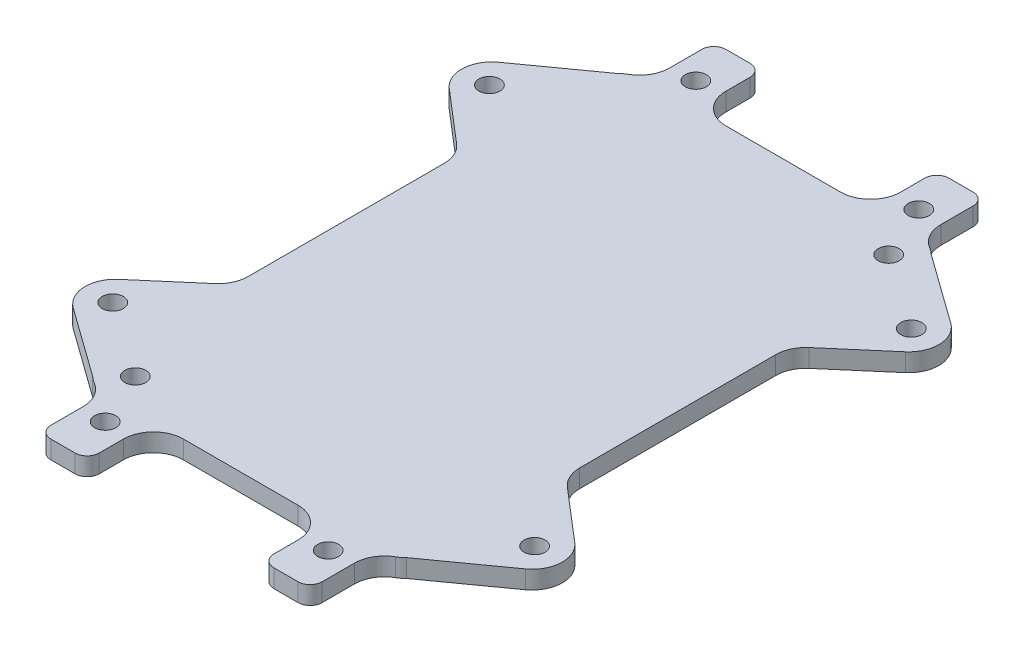
from build123d import *

# Parameters (mm, degrees)
SKETCH_1_R      = 1.75
EXTRUDE_1_DEPTH = 3
FILLET_3_R      = 5


with BuildPart() as part:
    # 草图1 → 凸台-拉伸1 (new body)
    with BuildSketch(Plane(origin=(0, 0, 0), x_dir=(1, 0, 0), z_dir=(0, 1, 0))):
        with BuildLine():
            Line((-27.5, -18.562205506), (-37.85023308, -27.436866757))
            ThreePointArc((-37.85023308, -27.436866757), (-39.59101252, -31.447551796), (-37.512145027, -35.293876989))
            Line((-37.512145027, -35.293876989), (-26.035533906, -43.535533906))
            ThreePointArc((-26.035533906, -43.535533906), (-24.413417162, -44.619397663), (-22.5, -45))
            Line((-22.5, -45), (-22.5, -54))
            ThreePointArc((-22.5, -54), (-21.914213562, -55.414213562), (-20.5, -56))
            Line((-20.5, -56), (-16.5, -56))
            ThreePointArc((-16.5, -56), (-15.085786438, -55.414213562), (-14.5, -54))
            Line((-14.5, -54), (-14.5, -45))
            Line((-14.5, -45), (14.5, -45))
            Line((14.5, -45), (14.5, -54))
            ThreePointArc((14.5, -54), (15.085786438, -55.414213562), (16.5, -56))
            Line((16.5, -56), (20.5, -56))
            ThreePointArc((20.5, -56), (21.914213562, -55.414213562), (22.5, -54))
            Line((22.5, -54), (22.5, -45))
            ThreePointArc((22.5, -45), (24.413417162, -44.619397663), (26.035533906, -43.535533906))
            Line((26.035533906, -43.535533906), (37.512145027, -35.293876989))
            ThreePointArc((37.512145027, -35.293876989), (39.59101252, -31.447551796), (37.85023308, -27.436866757))
            Line((37.85023308, -27.436866757), (27.5, -18.562205506))
            Line((27.5, -18.562205506), (27.5, 18.562205506))
            Line((27.5, 18.562205506), (37.85023308, 27.436866757))
            ThreePointArc((37.85023308, 27.436866757), (39.59101252, 31.447551796), (37.512145027, 35.293876989))
            Line((37.512145027, 35.293876989), (26.035533906, 43.535533906))
            ThreePointArc((26.035533906, 43.535533906), (24.413417162, 44.619397663), (22.5, 45))
            Line((22.5, 45), (22.5, 54))
            ThreePointArc((22.5, 54), (21.914213562, 55.414213562), (20.5, 56))
            Line((20.5, 56), (16.5, 56))
            ThreePointArc((16.5, 56), (15.085786438, 55.414213562), (14.5, 54))
            Line((14.5, 54), (14.5, 45))
            Line((14.5, 45), (-14.5, 45))
            Line((-14.5, 45), (-14.5, 54))
            ThreePointArc((-14.5, 54), (-15.085786438, 55.414213562), (-16.5, 56))
            Line((-16.5, 56), (-20.5, 56))
            ThreePointArc((-20.5, 56), (-21.914213562, 55.414213562), (-22.5, 54))
            Line((-22.5, 54), (-22.5, 45))
            ThreePointArc((-22.5, 45), (-24.413417162, 44.619397663), (-26.035533906, 43.535533906))
            Line((-26.035533906, 43.535533906), (-37.512145027, 35.293876989))
            ThreePointArc((-37.512145027, 35.293876989), (-39.59101252, 31.447551796), (-37.85023308, 27.436866757))
            Line((-37.85023308, 27.436866757), (-27.5, 18.562205506))
            Line((-27.5, 18.562205506), (-27.5, -18.562205506))
        make_face()
        with Locations((-22.5, -40)):
            Circle(SKETCH_1_R, mode=Mode.SUBTRACT)
        with Locations((22.5, 40)):
            Circle(SKETCH_1_R, mode=Mode.SUBTRACT)
        with Locations((-35, -31.25)):
            Circle(SKETCH_1_R, mode=Mode.SUBTRACT)
        with Locations((-18.5, -49)):
            Circle(SKETCH_1_R, mode=Mode.SUBTRACT)
        with Locations((18.5, -49)):
            Circle(SKETCH_1_R, mode=Mode.SUBTRACT)
        with Locations((-35, 31.25)):
            Circle(SKETCH_1_R, mode=Mode.SUBTRACT)
        with Locations((35, -31.25)):
            Circle(SKETCH_1_R, mode=Mode.SUBTRACT)
        with Locations((-18.5, 49)):
            Circle(SKETCH_1_R, mode=Mode.SUBTRACT)
        with Locations((35, 31.25)):
            Circle(SKETCH_1_R, mode=Mode.SUBTRACT)
        with Locations((18.5, 49)):
            Circle(SKETCH_1_R, mode=Mode.SUBTRACT)
    extrude(amount=EXTRUDE_1_DEPTH)

    # 圆角3
    fillet_3_edges = [part.edges().sort_by_distance(p)[0] for p in [
        (-22.5, 1.5, -45),
        (-14.5, 1.5, -45),
        (14.5, 1.5, -45),
        (22.5, 1.5, -45),
        (27.5, 1.5, -18.562205506),
        (27.5, 1.5, 18.562205506),
        (22.5, 1.5, 45),
        (14.5, 1.5, 45),
        (-14.5, 1.5, 45),
        (-22.5, 1.5, 45),
        (-27.5, 1.5, 18.562205506),
        (-27.5, 1.5, -18.562205506),
    ]]
    fillet(fillet_3_edges, radius=FILLET_3_R)


solid = part.part
